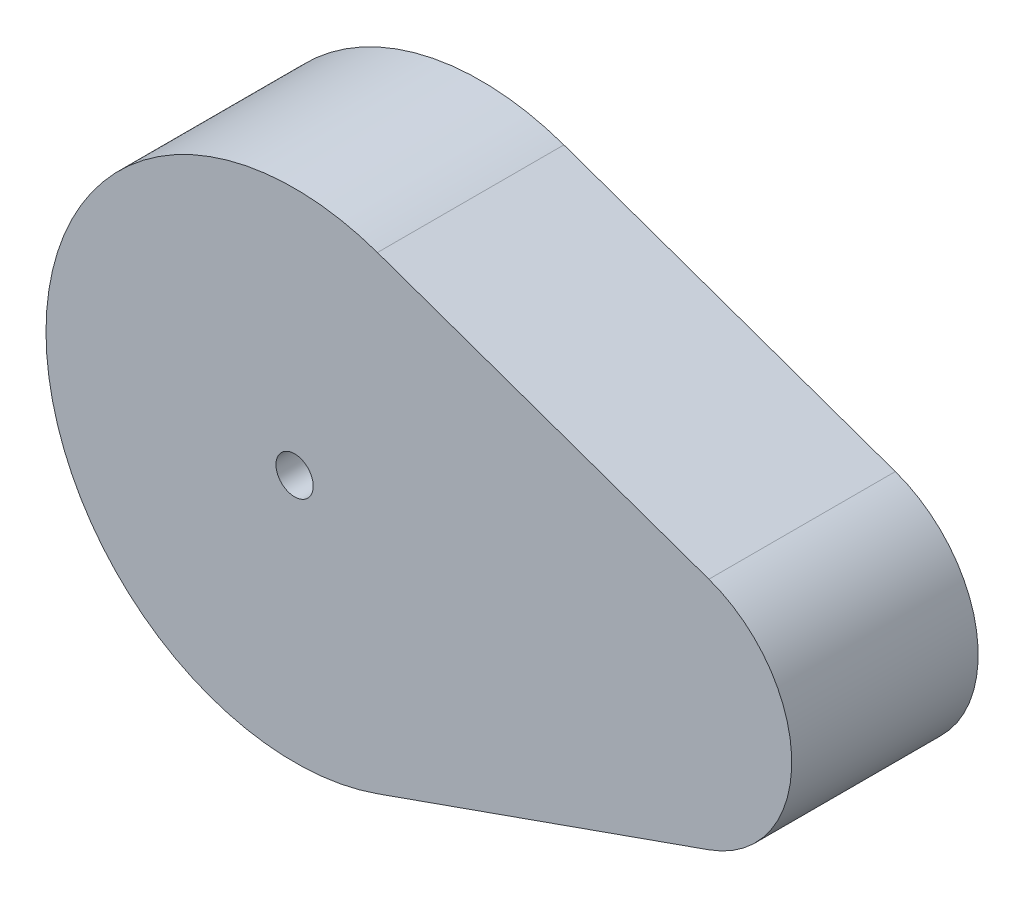
from build123d import *

# Parameters (mm, degrees)
SKETCH1_R           = 0.6
BOSS_EXTRUDE1_DEPTH = 6


with BuildPart() as part:
    # Sketch1 → Boss-Extrude1 (new body)
    with BuildSketch(Plane.XY):
        with BuildLine():
            Line((2.666666667, 7.542472333), (13.333333333, 3.771236166))
            ThreePointArc((13.333333333, 3.771236166), (16, 0), (13.333333333, -3.771236166))
            Line((13.333333333, -3.771236166), (2.666666667, -7.542472333))
            ThreePointArc((2.666666667, -7.542472333), (-8, 0), (2.666666667, 7.542472333))
        make_face()
        Circle(SKETCH1_R, mode=Mode.SUBTRACT)
    extrude(amount=-BOSS_EXTRUDE1_DEPTH)


solid = part.part
